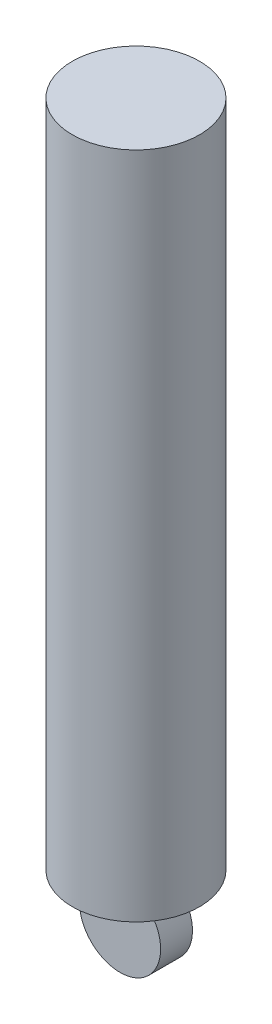
from build123d import *

# Parameters (mm, degrees)
SKETCH1_R           = 25.4
BOSS_EXTRUDE1_DEPTH = 266.7
SKETCH3_R           = 16.198016886
BOSS_EXTRUDE2_DEPTH = 6.35


with BuildPart() as part:
    # Sketch1 → Boss-Extrude1 (new body)
    with BuildSketch(Plane(origin=(0, 0, 0), x_dir=(1, 0, 0), z_dir=(0, 1, 0))):
        Circle(SKETCH1_R)
    extrude(amount=BOSS_EXTRUDE1_DEPTH)

    # Sketch3 → Boss-Extrude2 (add, symmetric)
    with BuildSketch(Plane.XY):
        with Locations((0, -16.03996745)):
            Circle(SKETCH3_R)
    extrude(amount=BOSS_EXTRUDE2_DEPTH, both=True)


solid = part.part
